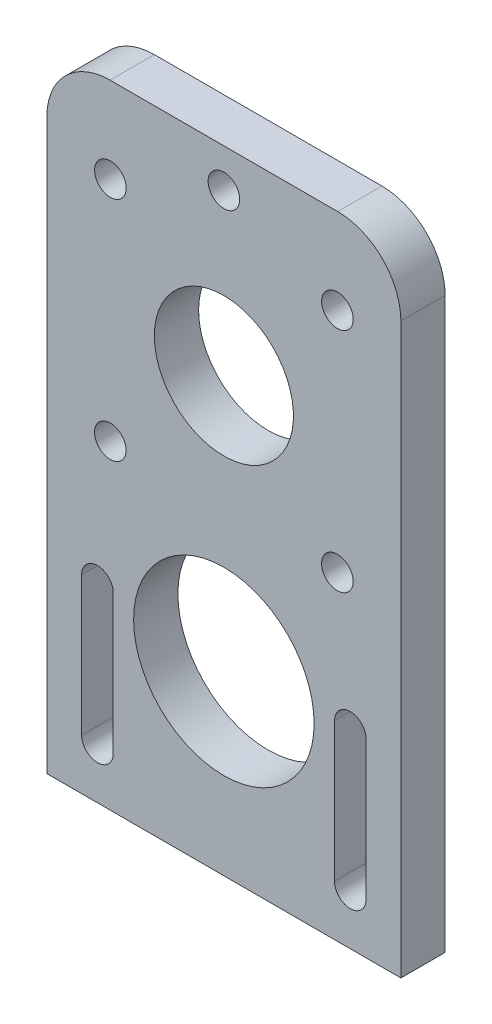
from build123d import *

# Parameters (mm, degrees)
SKETCH1_W           = 56
SKETCH1_H           = 100
BOSS_EXTRUDE1_DEPTH = 7
SKETCH2_R           = 14.275
CUT_EXTRUDE1_DEPTH  = 8
SKETCH3_R           = 11
CUT_EXTRUDE2_DEPTH  = 10
SKETCH4_R           = 2.5
CUT_EXTRUDE3_DEPTH  = 8
FILLET1_R           = 10


with BuildPart() as part:
    # Sketch1 → Boss-Extrude1 (new body)
    with BuildSketch(Plane.XY):
        with Locations((28, 50)):
            Rectangle(SKETCH1_W, SKETCH1_H)
    extrude(amount=BOSS_EXTRUDE1_DEPTH)

    # Sketch2 → Cut-Extrude1 (cut, through all)
    with BuildSketch(Plane.XY.offset(7)):
        with Locations((28, 28)):
            Circle(SKETCH2_R)
        with BuildLine():
            Line((10.5, 30), (10.5, 8))
            ThreePointArc((10.5, 8), (8, 5.5), (5.5, 8))
            Line((5.5, 8), (5.5, 30))
            ThreePointArc((5.5, 30), (8, 32.5), (10.5, 30))
        make_face()
        with BuildLine():
            Line((50.5, 30), (50.5, 8))
            ThreePointArc((50.5, 8), (48, 5.5), (45.5, 8))
            Line((45.5, 8), (45.5, 30))
            ThreePointArc((45.5, 30), (48, 32.5), (50.5, 30))
        make_face()
    extrude(amount=-CUT_EXTRUDE1_DEPTH, mode=Mode.SUBTRACT)

    # Sketch3 → Cut-Extrude2 (cut)
    with BuildSketch(Plane(origin=(0, 0, 0), x_dir=(-1, 0, 0), z_dir=(0, 0, -1))):
        with Locations((-28, 68.5)):
            Circle(SKETCH3_R)
    extrude(amount=-CUT_EXTRUDE2_DEPTH, mode=Mode.SUBTRACT)

    # Sketch4 → Cut-Extrude3 (cut, through all)
    with BuildSketch(Plane(origin=(0, 0, 0), x_dir=(-1, 0, 0), z_dir=(0, 0, -1))):
        with Locations((-45.965981938, 86.45504088)):
            Circle(SKETCH4_R)
        with Locations((-28.007736497, 93.899998822)):
            Circle(SKETCH4_R)
        with Locations((-10.04495912, 86.465981938)):
            Circle(SKETCH4_R)
        with Locations((-45.95504088, 50.534018062)):
            Circle(SKETCH4_R)
        with Locations((-10.034018062, 50.54495912)):
            Circle(SKETCH4_R)
    extrude(amount=-CUT_EXTRUDE3_DEPTH, mode=Mode.SUBTRACT)

    # Fillet1
    fillet1_edges = [part.edges().sort_by_distance(p)[0] for p in [
        (56, 100, 3.5),
        (0, 100, 3.5),
    ]]
    fillet(fillet1_edges, radius=FILLET1_R)


solid = part.part
